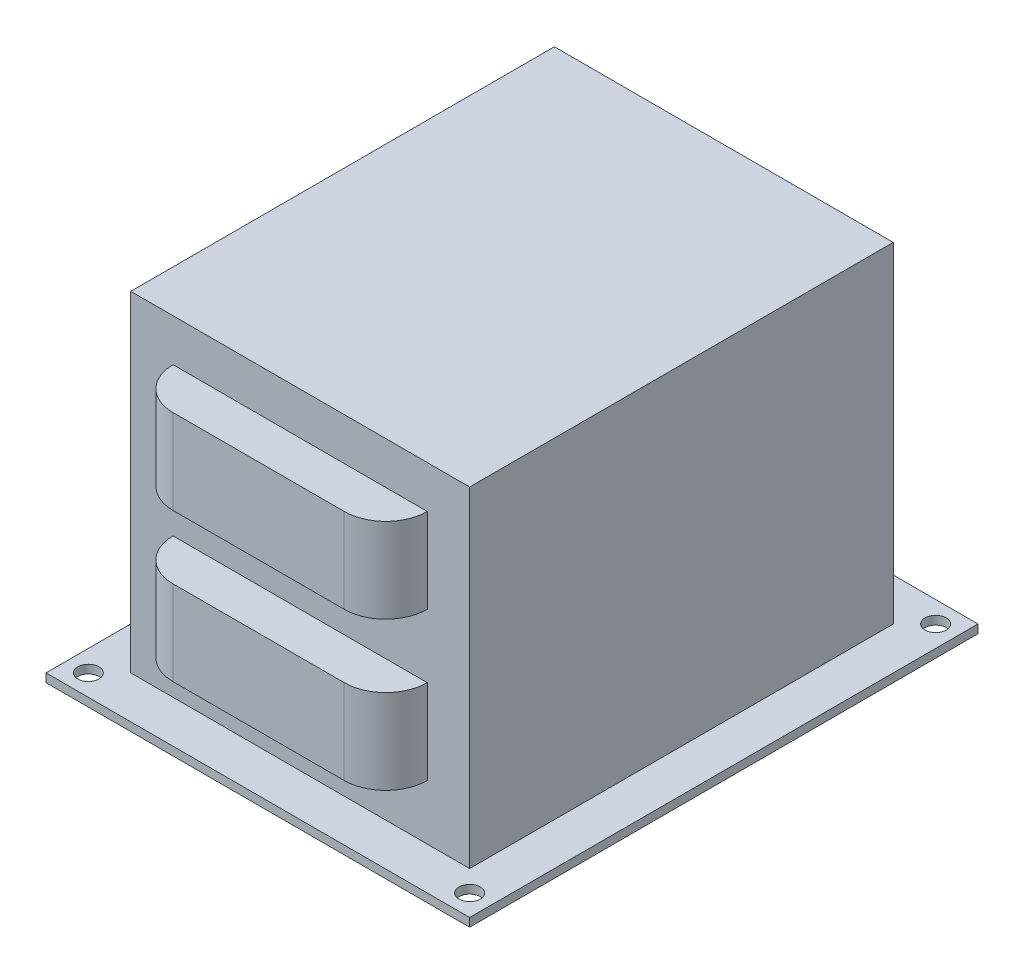
from build123d import *

# Parameters (mm, degrees)
SKETCH1_W           = 127
SKETCH1_H           = 152.4
SKETCH1_R           = 3.175
SKETCH1_W_2         = 101.6
SKETCH1_H_2         = 127
BOSS_EXTRUDE1_DEPTH = 2.54
SKETCH1_4_W         = 101.6
SKETCH1_4_H         = 127
BOSS_EXTRUDE2_DEPTH = 101.6
BOSS_EXTRUDE3_START = 63.5
BOSS_EXTRUDE3_DEPTH = 25.4
BOSS_EXTRUDE4_START = 19.05
BOSS_EXTRUDE4_DEPTH = 25.4


with BuildPart() as part:
    # Sketch1 → Boss-Extrude1 (new body)
    with BuildSketch(Plane(origin=(0, 0, 0), x_dir=(1, 0, 0), z_dir=(0, 1, 0))):
        Rectangle(SKETCH1_W, SKETCH1_H)
        with Locations((-57.15, -69.85)):
            Circle(SKETCH1_R, mode=Mode.SUBTRACT)
        with Locations((57.15, -69.85)):
            Circle(SKETCH1_R, mode=Mode.SUBTRACT)
        with BuildLine():
            Line((-50.8, -63.5), (-50.8, 63.5))
            Line((-50.8, 63.5), (-38.1, 63.5))
            ThreePointArc((-38.1, 63.5), (-34.454650999, 72.300650999), (-25.654, 75.946))
            Line((-25.654, 75.946), (25.654, 75.946))
            ThreePointArc((25.654, 75.946), (34.454650999, 72.300650999), (38.1, 63.5))
            Line((38.1, 63.5), (50.8, 63.5))
            Line((50.8, 63.5), (50.8, -63.5))
            Line((50.8, -63.5), (38.1, -63.5))
            ThreePointArc((38.1, -63.5), (34.454650999, -72.300650999), (25.654, -75.946))
            Line((25.654, -75.946), (-25.654, -75.946))
            ThreePointArc((-25.654, -75.946), (-34.454650999, -72.300650999), (-38.1, -63.5))
            Line((-38.1, -63.5), (-50.8, -63.5))
        make_face(mode=Mode.SUBTRACT)
        with Locations((-57.15, 69.85)):
            Circle(SKETCH1_R, mode=Mode.SUBTRACT)
        with Locations((57.15, 69.85)):
            Circle(SKETCH1_R, mode=Mode.SUBTRACT)
        with BuildLine():
            Line((38.1, -63.5), (-38.1, -63.5))
            ThreePointArc((-38.1, -63.5), (-34.454650999, -72.300650999), (-25.654, -75.946))
            Line((-25.654, -75.946), (25.654, -75.946))
            ThreePointArc((25.654, -75.946), (34.454650999, -72.300650999), (38.1, -63.5))
        make_face()
        Rectangle(SKETCH1_W_2, SKETCH1_H_2)
        with BuildLine():
            ThreePointArc((-25.654, 75.946), (-34.454650999, 72.300650999), (-38.1, 63.5))
            Line((-38.1, 63.5), (38.1, 63.5))
            ThreePointArc((38.1, 63.5), (34.454650999, 72.300650999), (25.654, 75.946))
            Line((25.654, 75.946), (-25.654, 75.946))
        make_face()
    extrude(amount=BOSS_EXTRUDE1_DEPTH)

    # Sketch1_4 → Boss-Extrude2 (add)
    with BuildSketch(Plane(origin=(0, 0, 0), x_dir=(1, 0, 0), z_dir=(0, 1, 0))):
        Rectangle(SKETCH1_4_W, SKETCH1_4_H)
    extrude(amount=BOSS_EXTRUDE2_DEPTH)

    # Sketch1_5 → Boss-Extrude3 (add)
    with BuildSketch(Plane(origin=(0, 0, 0), x_dir=(1, 0, 0), z_dir=(0, 1, 0)).offset(BOSS_EXTRUDE3_START)):
        with BuildLine():
            Line((38.1, -63.5), (-38.1, -63.5))
            ThreePointArc((-38.1, -63.5), (-34.454650999, -72.300650999), (-25.654, -75.946))
            Line((-25.654, -75.946), (25.654, -75.946))
            ThreePointArc((25.654, -75.946), (34.454650999, -72.300650999), (38.1, -63.5))
        make_face()
        with BuildLine():
            Line((25.654, 75.946), (-25.654, 75.946))
            ThreePointArc((-25.654, 75.946), (-34.454650999, 72.300650999), (-38.1, 63.5))
            Line((-38.1, 63.5), (38.1, 63.5))
            ThreePointArc((38.1, 63.5), (34.454650999, 72.300650999), (25.654, 75.946))
        make_face()
    extrude(amount=BOSS_EXTRUDE3_DEPTH)

    # Sketch1_6 → Boss-Extrude4 (add)
    with BuildSketch(Plane(origin=(0, 0, 0), x_dir=(1, 0, 0), z_dir=(0, 1, 0)).offset(BOSS_EXTRUDE4_START)):
        with BuildLine():
            Line((38.1, -63.5), (-38.1, -63.5))
            ThreePointArc((-38.1, -63.5), (-34.454650999, -72.300650999), (-25.654, -75.946))
            Line((-25.654, -75.946), (25.654, -75.946))
            ThreePointArc((25.654, -75.946), (34.454650999, -72.300650999), (38.1, -63.5))
        make_face()
        with BuildLine():
            ThreePointArc((-25.654, 75.946), (-34.454650999, 72.300650999), (-38.1, 63.5))
            Line((-38.1, 63.5), (38.1, 63.5))
            ThreePointArc((38.1, 63.5), (34.454650999, 72.300650999), (25.654, 75.946))
            Line((25.654, 75.946), (-25.654, 75.946))
        make_face()
    extrude(amount=BOSS_EXTRUDE4_DEPTH)


solid = part.part
